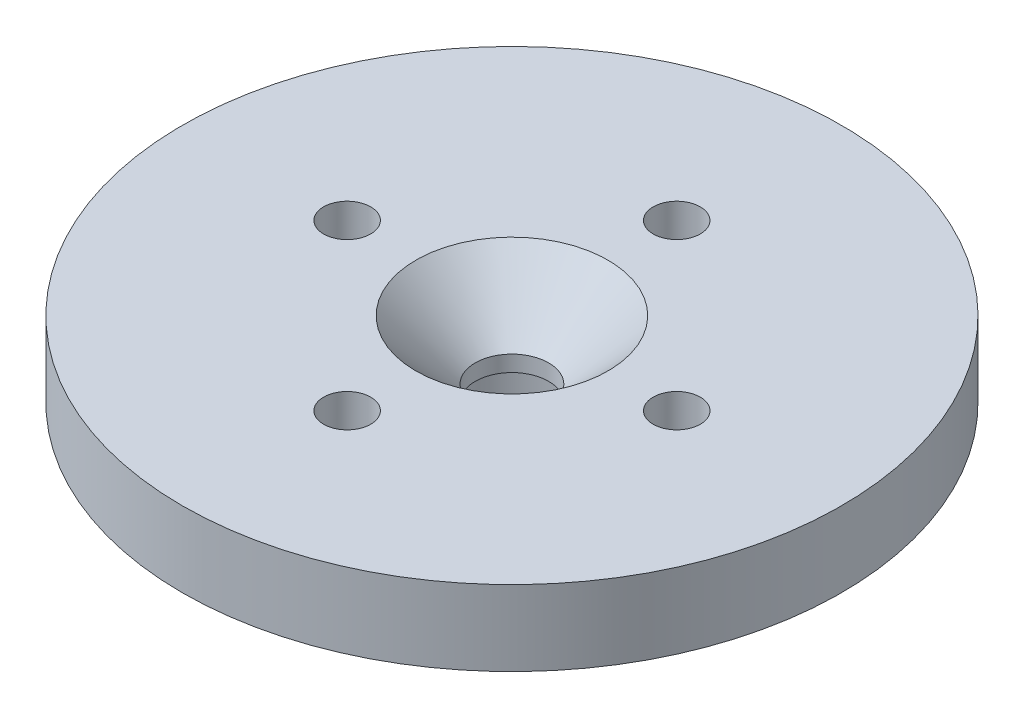
from build123d import *

# Parameters (mm, degrees)
SKETCH1_R                                         = 17.5
BOSS_EXTRUDE1_DEPTH                               = 4
SKETCH2_R                                         = 5
SKETCH2_R_2                                       = 4
BOSS_EXTRUDE2_DEPTH                               = 6.9
SKETCH3_R                                         = 1.25
CUT_EXTRUDE1_DEPTH                                = 6.9
CSK_FOR_M3_5_FLAT_HEAD_MACHINE_SCREW1_D           = 3.9
CSK_FOR_M3_5_FLAT_HEAD_MACHINE_SCREW1_CSINK_D     = 10.2
CSK_FOR_M3_5_FLAT_HEAD_MACHINE_SCREW1_CSINK_ANGLE = 90
SKETCH6_R                                         = 1.25
CUT_EXTRUDE2_DEPTH                                = 6.9


with BuildPart() as part:
    # Sketch1 → Boss-Extrude1 (new body)
    with BuildSketch(Plane(origin=(0, 0, 0), x_dir=(1, 0, 0), z_dir=(0, 1, 0))):
        Circle(SKETCH1_R)
    extrude(amount=BOSS_EXTRUDE1_DEPTH)

    # Sketch2 → Boss-Extrude2 (add)
    with BuildSketch(Plane.XZ):
        Circle(SKETCH2_R)
        Circle(SKETCH2_R_2, mode=Mode.SUBTRACT)
    extrude(amount=BOSS_EXTRUDE2_DEPTH)

    # Sketch3 → Cut-Extrude1 (cut)
    with BuildSketch(Plane.XZ):
        with Locations((-8.75, 0)):
            Circle(SKETCH3_R)
        with Locations((8.75, 0)):
            Circle(SKETCH3_R)
    extrude(amount=-CUT_EXTRUDE1_DEPTH, mode=Mode.SUBTRACT)

    # CSK for M3.5 Flat Head Machine Screw1 (through all)
    with Locations(Plane(origin=(0, 4, 0), x_dir=(1, 0, 0), z_dir=(0, 1, 0))):
        with Locations((0, 0)):
            CounterSinkHole(CSK_FOR_M3_5_FLAT_HEAD_MACHINE_SCREW1_D / 2, CSK_FOR_M3_5_FLAT_HEAD_MACHINE_SCREW1_CSINK_D / 2, counter_sink_angle=CSK_FOR_M3_5_FLAT_HEAD_MACHINE_SCREW1_CSINK_ANGLE)

    # Sketch6 → Cut-Extrude2 (cut)
    with BuildSketch(Plane.XZ):
        with Locations((0, 8.75)):
            Circle(SKETCH6_R)
        with Locations((0, -8.75)):
            Circle(SKETCH6_R)
    extrude(amount=-CUT_EXTRUDE2_DEPTH, mode=Mode.SUBTRACT)


solid = part.part
